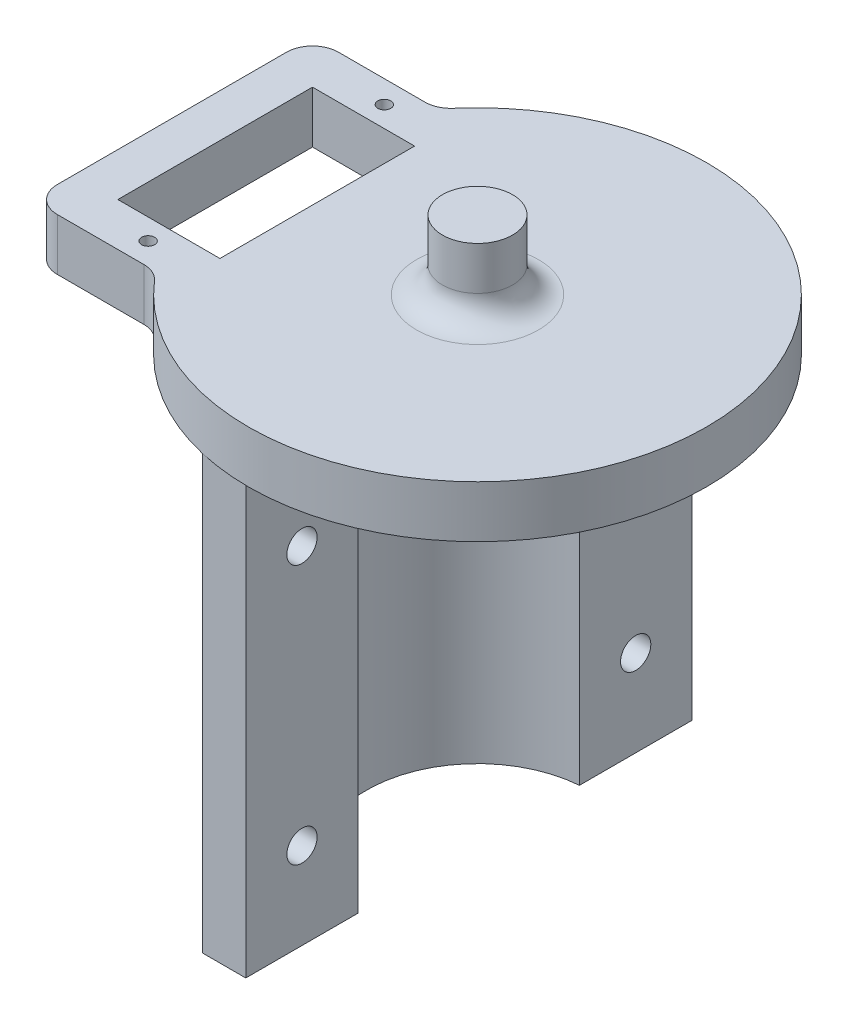
from build123d import *

# Parameters (mm, degrees)
BOSS_EXTRUDE4_DEPTH = 50
SKETCH7_R           = 1.75
CUT_EXTRUDE1_DEPTH  = 17.825
SKETCH8_R           = 0.75
SKETCH8_W           = 11.8
SKETCH8_H           = 22.5
BOSS_EXTRUDE5_DEPTH = 6
SKETCH9_R           = 4.05
BOSS_EXTRUDE6_DEPTH = 8
FILLET1_R           = 3


with BuildPart() as part:
    # Sketch6 → Boss-Extrude4 (new body)
    with BuildSketch(Plane.XZ):
        with BuildLine():
            Line((-1, 25.784833184), (-1, 12.785954208))
            ThreePointArc((-1, 12.785954208), (-12.825, 0), (-1, -12.785954208))
            Line((-1, -12.785954208), (-1, -25.784833184))
            Line((-1, -25.784833184), (-6, -25.784833184))
            Line((-6, -25.784833184), (-6, -16.784833184))
            ThreePointArc((-6, -16.784833184), (-17.825, 0), (-6, 16.784833184))
            Line((-6, 16.784833184), (-6, 25.784833184))
            Line((-6, 25.784833184), (-1, 25.784833184))
        make_face()
    extrude(amount=BOSS_EXTRUDE4_DEPTH)

    # Sketch7 → Cut-Extrude1 (cut, through all)
    with BuildSketch(Plane(origin=(-1, 0, 0), x_dir=(0, 0, -1), z_dir=(1, 0, 0))):
        with Locations((-19.285393696, -10)):
            Circle(SKETCH7_R)
        with Locations((-19.285393696, -40)):
            Circle(SKETCH7_R)
        with Locations((19.285393696, -40)):
            Circle(SKETCH7_R)
        with Locations((19.285393696, -10)):
            Circle(SKETCH7_R)
    extrude(amount=-CUT_EXTRUDE1_DEPTH, mode=Mode.SUBTRACT)

    # Sketch8 → Boss-Extrude5 (add)
    with BuildSketch(Plane(origin=(0, 0, 0), x_dir=(1, 0, 0), z_dir=(0, 1, 0))):
        with BuildLine():
            Line((-32.320841509, -16.25), (-22.318992281, -16.25))
            ThreePointArc((-22.318992281, -16.25), (-21.069616181, -16.522536094), (-20.047240136, -17.290627093))
            ThreePointArc((-20.047240136, -17.290627093), (26.473715688, 0), (-20.047240136, 17.290627093))
            ThreePointArc((-20.047240136, 17.290627093), (-21.069616181, 16.522536094), (-22.318992281, 16.25))
            Line((-22.318992281, 16.25), (-32.320841509, 16.25))
            ThreePointArc((-32.320841509, 16.25), (-34.442161852, 15.371320344), (-35.320841509, 13.25))
            Line((-35.320841509, 13.25), (-35.320841509, -13.25))
            ThreePointArc((-35.320841509, -13.25), (-34.442161852, -15.371320344), (-32.320841509, -16.25))
        make_face()
        with Locations((-24.420841509, 13.65)):
            Circle(SKETCH8_R, mode=Mode.SUBTRACT)
        with Locations((-24.420841509, -13.65)):
            Circle(SKETCH8_R, mode=Mode.SUBTRACT)
        with Locations((-24.420841509, 0)):
            Rectangle(SKETCH8_W, SKETCH8_H, mode=Mode.SUBTRACT)
    extrude(amount=BOSS_EXTRUDE5_DEPTH)

    # Sketch9 → Boss-Extrude6 (add)
    with BuildSketch(Plane(origin=(0, 6, 0), x_dir=(1, 0, 0), z_dir=(0, 1, 0))):
        Circle(SKETCH9_R)
    extrude(amount=BOSS_EXTRUDE6_DEPTH)

    # Fillet1
    fillet1_edges = [part.edges().sort_by_distance(p)[0] for p in [
        (-4.05, 6, 0),
    ]]
    fillet(fillet1_edges, radius=FILLET1_R)


solid = part.part
